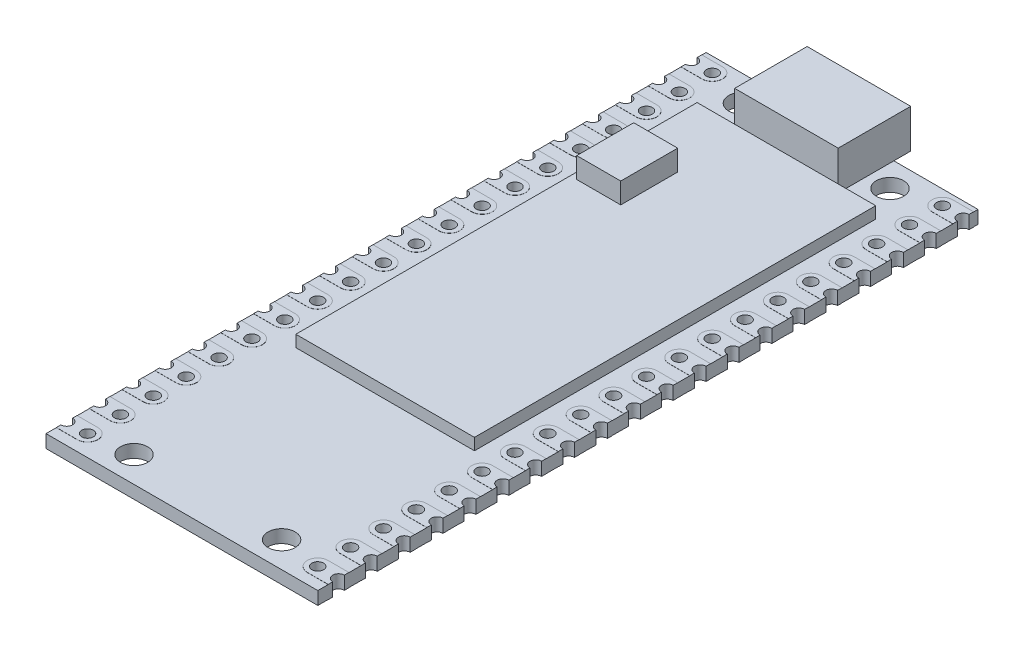
from build123d import *

# Parameters (mm, degrees)
SKETCH1_R                = 1.05
SKETCH1_R_2              = 0.45
BOSS_EXTRUDE1_DEPTH      = 1
SKETCH2_W                = 8
SKETCH2_H                = 5.6
BOSS_EXTRUDE2_DEPTH      = 3
SKETCH3_R                = 0.45
BOSS_EXTRUDE3_DEPTH      = 0.01
BOSS_EXTRUDE3_DEPTH_BACK = 1.01
SKETCH4_W                = 13.8
SKETCH4_H                = 31
BOSS_EXTRUDE4_DEPTH      = 0.9
SKETCH5_W                = 3.4
SKETCH5_H                = 4.4
BOSS_EXTRUDE5_DEPTH      = 2.5


with BuildPart() as part:
    # Sketch1 → Boss-Extrude1 (new body)
    with BuildSketch(Plane(origin=(0, 0, 0), x_dir=(1, 0, 0), z_dir=(0, 1, 0))):
        with BuildLine():
            Line((-10.5, 0), (10.5, 0))
            Line((10.5, 0), (10.5, -0.69))
            ThreePointArc((10.5, -0.69), (10.05, -1.14), (10.5, -1.59))
            Line((10.5, -1.59), (10.5, -3.23))
            ThreePointArc((10.5, -3.23), (10.05, -3.68), (10.5, -4.13))
            Line((10.5, -4.13), (10.5, -5.77))
            ThreePointArc((10.5, -5.77), (10.05, -6.22), (10.5, -6.67))
            Line((10.5, -6.67), (10.5, -8.31))
            ThreePointArc((10.5, -8.31), (10.05, -8.76), (10.5, -9.21))
            Line((10.5, -9.21), (10.5, -10.85))
            ThreePointArc((10.5, -10.85), (10.05, -11.3), (10.5, -11.75))
            Line((10.5, -11.75), (10.5, -13.39))
            ThreePointArc((10.5, -13.39), (10.05, -13.84), (10.5, -14.29))
            Line((10.5, -14.29), (10.5, -15.93))
            ThreePointArc((10.5, -15.93), (10.05, -16.38), (10.5, -16.83))
            Line((10.5, -16.83), (10.5, -18.47))
            ThreePointArc((10.5, -18.47), (10.05, -18.92), (10.5, -19.37))
            Line((10.5, -19.37), (10.5, -21.01))
            ThreePointArc((10.5, -21.01), (10.05, -21.46), (10.5, -21.91))
            Line((10.5, -21.91), (10.5, -23.55))
            ThreePointArc((10.5, -23.55), (10.05, -24), (10.5, -24.45))
            Line((10.5, -24.45), (10.5, -26.09))
            ThreePointArc((10.5, -26.09), (10.05, -26.54), (10.5, -26.99))
            Line((10.5, -26.99), (10.5, -28.63))
            ThreePointArc((10.5, -28.63), (10.05, -29.08), (10.5, -29.53))
            Line((10.5, -29.53), (10.5, -31.17))
            ThreePointArc((10.5, -31.17), (10.05, -31.62), (10.5, -32.07))
            Line((10.5, -32.07), (10.5, -33.71))
            ThreePointArc((10.5, -33.71), (10.05, -34.16), (10.5, -34.61))
            Line((10.5, -34.61), (10.5, -36.25))
            ThreePointArc((10.5, -36.25), (10.05, -36.7), (10.5, -37.15))
            Line((10.5, -37.15), (10.5, -38.79))
            ThreePointArc((10.5, -38.79), (10.05, -39.24), (10.5, -39.69))
            Line((10.5, -39.69), (10.5, -41.33))
            ThreePointArc((10.5, -41.33), (10.05, -41.78), (10.5, -42.23))
            Line((10.5, -42.23), (10.5, -43.87))
            ThreePointArc((10.5, -43.87), (10.05, -44.32), (10.5, -44.77))
            Line((10.5, -44.77), (10.5, -46.41))
            ThreePointArc((10.5, -46.41), (10.05, -46.86), (10.5, -47.31))
            Line((10.5, -47.31), (10.5, -48.95))
            ThreePointArc((10.5, -48.95), (10.05, -49.4), (10.5, -49.85))
            Line((10.5, -49.85), (10.5, -51))
            Line((10.5, -51), (-10.5, -51))
            Line((-10.5, -51), (-10.5, -49.85))
            ThreePointArc((-10.5, -49.85), (-10.05, -49.4), (-10.5, -48.95))
            Line((-10.5, -48.95), (-10.5, -47.31))
            ThreePointArc((-10.5, -47.31), (-10.05, -46.86), (-10.5, -46.41))
            Line((-10.5, -46.41), (-10.5, -44.77))
            ThreePointArc((-10.5, -44.77), (-10.05, -44.32), (-10.5, -43.87))
            Line((-10.5, -43.87), (-10.5, -42.23))
            ThreePointArc((-10.5, -42.23), (-10.05, -41.78), (-10.5, -41.33))
            Line((-10.5, -41.33), (-10.5, -39.69))
            ThreePointArc((-10.5, -39.69), (-10.05, -39.24), (-10.5, -38.79))
            Line((-10.5, -38.79), (-10.5, -37.15))
            ThreePointArc((-10.5, -37.15), (-10.05, -36.7), (-10.5, -36.25))
            Line((-10.5, -36.25), (-10.5, -34.61))
            ThreePointArc((-10.5, -34.61), (-10.05, -34.16), (-10.5, -33.71))
            Line((-10.5, -33.71), (-10.5, -32.07))
            ThreePointArc((-10.5, -32.07), (-10.05, -31.62), (-10.5, -31.17))
            Line((-10.5, -31.17), (-10.5, -29.53))
            ThreePointArc((-10.5, -29.53), (-10.05, -29.08), (-10.5, -28.63))
            Line((-10.5, -28.63), (-10.5, -26.99))
            ThreePointArc((-10.5, -26.99), (-10.05, -26.54), (-10.5, -26.09))
            Line((-10.5, -26.09), (-10.5, -24.45))
            ThreePointArc((-10.5, -24.45), (-10.05, -24), (-10.5, -23.55))
            Line((-10.5, -23.55), (-10.5, -21.91))
            ThreePointArc((-10.5, -21.91), (-10.05, -21.46), (-10.5, -21.01))
            Line((-10.5, -21.01), (-10.5, -19.37))
            ThreePointArc((-10.5, -19.37), (-10.05, -18.92), (-10.5, -18.47))
            Line((-10.5, -18.47), (-10.5, -16.83))
            ThreePointArc((-10.5, -16.83), (-10.05, -16.38), (-10.5, -15.93))
            Line((-10.5, -15.93), (-10.5, -14.29))
            ThreePointArc((-10.5, -14.29), (-10.05, -13.84), (-10.5, -13.39))
            Line((-10.5, -13.39), (-10.5, -11.75))
            ThreePointArc((-10.5, -11.75), (-10.05, -11.3), (-10.5, -10.85))
            Line((-10.5, -10.85), (-10.5, -9.21))
            ThreePointArc((-10.5, -9.21), (-10.05, -8.76), (-10.5, -8.31))
            Line((-10.5, -8.31), (-10.5, -6.67))
            ThreePointArc((-10.5, -6.67), (-10.05, -6.22), (-10.5, -5.77))
            Line((-10.5, -5.77), (-10.5, -4.13))
            ThreePointArc((-10.5, -4.13), (-10.05, -3.68), (-10.5, -3.23))
            Line((-10.5, -3.23), (-10.5, -1.59))
            ThreePointArc((-10.5, -1.59), (-10.05, -1.14), (-10.5, -0.69))
            Line((-10.5, -0.69), (-10.5, 0))
        make_face()
        with Locations(Location((-5.7, -2, 0), (0, 0, 270))):
            Circle(SKETCH1_R, mode=Mode.SUBTRACT)
        with Locations(Location((5.7, -2, 0), (0, 0, 90))):
            Circle(SKETCH1_R, mode=Mode.SUBTRACT)
        with Locations(Location((-8.89, -49.4, 0), (0, 0, 270))):
            Circle(SKETCH1_R_2, mode=Mode.SUBTRACT)
        with Locations(Location((5.7, -49, 0), (0, 0, 270))):
            Circle(SKETCH1_R, mode=Mode.SUBTRACT)
        with Locations(Location((-5.7, -49, 0), (0, 0, 90))):
            Circle(SKETCH1_R, mode=Mode.SUBTRACT)
        with Locations(Location((8.89, -49.4, 0), (0, 0, 90))):
            Circle(SKETCH1_R_2, mode=Mode.SUBTRACT)
        with Locations(Location((-8.89, -46.86, 0), (0, 0, 270))):
            Circle(SKETCH1_R_2, mode=Mode.SUBTRACT)
        with Locations(Location((8.89, -46.86, 0), (0, 0, 90))):
            Circle(SKETCH1_R_2, mode=Mode.SUBTRACT)
        with Locations(Location((-8.89, -44.32, 0), (0, 0, 270))):
            Circle(SKETCH1_R_2, mode=Mode.SUBTRACT)
        with Locations(Location((8.89, -44.32, 0), (0, 0, 90))):
            Circle(SKETCH1_R_2, mode=Mode.SUBTRACT)
        with Locations(Location((-8.89, -41.78, 0), (0, 0, 270))):
            Circle(SKETCH1_R_2, mode=Mode.SUBTRACT)
        with Locations(Location((8.89, -41.78, 0), (0, 0, 90))):
            Circle(SKETCH1_R_2, mode=Mode.SUBTRACT)
        with Locations(Location((-8.89, -39.24, 0), (0, 0, 270))):
            Circle(SKETCH1_R_2, mode=Mode.SUBTRACT)
        with Locations(Location((8.89, -39.24, 0), (0, 0, 90))):
            Circle(SKETCH1_R_2, mode=Mode.SUBTRACT)
        with Locations(Location((-8.89, -36.7, 0), (0, 0, 270))):
            Circle(SKETCH1_R_2, mode=Mode.SUBTRACT)
        with Locations(Location((8.89, -36.7, 0), (0, 0, 90))):
            Circle(SKETCH1_R_2, mode=Mode.SUBTRACT)
        with Locations(Location((-8.89, -34.16, 0), (0, 0, 270))):
            Circle(SKETCH1_R_2, mode=Mode.SUBTRACT)
        with Locations(Location((8.89, -34.16, 0), (0, 0, 90))):
            Circle(SKETCH1_R_2, mode=Mode.SUBTRACT)
        with Locations(Location((-8.89, -31.62, 0), (0, 0, 270))):
            Circle(SKETCH1_R_2, mode=Mode.SUBTRACT)
        with Locations(Location((8.89, -31.62, 0), (0, 0, 90))):
            Circle(SKETCH1_R_2, mode=Mode.SUBTRACT)
        with Locations(Location((-8.89, -29.08, 0), (0, 0, 270))):
            Circle(SKETCH1_R_2, mode=Mode.SUBTRACT)
        with Locations(Location((8.89, -29.08, 0), (0, 0, 90))):
            Circle(SKETCH1_R_2, mode=Mode.SUBTRACT)
        with Locations(Location((-8.89, -26.54, 0), (0, 0, 270))):
            Circle(SKETCH1_R_2, mode=Mode.SUBTRACT)
        with Locations(Location((8.89, -26.54, 0), (0, 0, 90))):
            Circle(SKETCH1_R_2, mode=Mode.SUBTRACT)
        with Locations(Location((-8.89, -24, 0), (0, 0, 270))):
            Circle(SKETCH1_R_2, mode=Mode.SUBTRACT)
        with Locations(Location((8.89, -24, 0), (0, 0, 90))):
            Circle(SKETCH1_R_2, mode=Mode.SUBTRACT)
        with Locations(Location((-8.89, -21.46, 0), (0, 0, 270))):
            Circle(SKETCH1_R_2, mode=Mode.SUBTRACT)
        with Locations(Location((8.89, -21.46, 0), (0, 0, 90))):
            Circle(SKETCH1_R_2, mode=Mode.SUBTRACT)
        with Locations(Location((-8.89, -18.92, 0), (0, 0, 270))):
            Circle(SKETCH1_R_2, mode=Mode.SUBTRACT)
        with Locations(Location((8.89, -18.92, 0), (0, 0, 90))):
            Circle(SKETCH1_R_2, mode=Mode.SUBTRACT)
        with Locations(Location((-8.89, -16.38, 0), (0, 0, 270))):
            Circle(SKETCH1_R_2, mode=Mode.SUBTRACT)
        with Locations(Location((8.89, -16.38, 0), (0, 0, 90))):
            Circle(SKETCH1_R_2, mode=Mode.SUBTRACT)
        with Locations(Location((-8.89, -13.84, 0), (0, 0, 270))):
            Circle(SKETCH1_R_2, mode=Mode.SUBTRACT)
        with Locations(Location((8.89, -13.84, 0), (0, 0, 90))):
            Circle(SKETCH1_R_2, mode=Mode.SUBTRACT)
        with Locations(Location((-8.89, -11.3, 0), (0, 0, 270))):
            Circle(SKETCH1_R_2, mode=Mode.SUBTRACT)
        with Locations(Location((8.89, -11.3, 0), (0, 0, 90))):
            Circle(SKETCH1_R_2, mode=Mode.SUBTRACT)
        with Locations(Location((-8.89, -8.76, 0), (0, 0, 270))):
            Circle(SKETCH1_R_2, mode=Mode.SUBTRACT)
        with Locations(Location((8.89, -8.76, 0), (0, 0, 90))):
            Circle(SKETCH1_R_2, mode=Mode.SUBTRACT)
        with Locations(Location((-8.89, -6.22, 0), (0, 0, 270))):
            Circle(SKETCH1_R_2, mode=Mode.SUBTRACT)
        with Locations(Location((8.89, -6.22, 0), (0, 0, 90))):
            Circle(SKETCH1_R_2, mode=Mode.SUBTRACT)
        with Locations(Location((-8.89, -3.68, 0), (0, 0, 270))):
            Circle(SKETCH1_R_2, mode=Mode.SUBTRACT)
        with Locations(Location((8.89, -3.68, 0), (0, 0, 90))):
            Circle(SKETCH1_R_2, mode=Mode.SUBTRACT)
        with Locations(Location((-8.89, -1.14, 0), (0, 0, 270))):
            Circle(SKETCH1_R_2, mode=Mode.SUBTRACT)
        with Locations(Location((8.89, -1.14, 0), (0, 0, 90))):
            Circle(SKETCH1_R_2, mode=Mode.SUBTRACT)
    extrude(amount=BOSS_EXTRUDE1_DEPTH)

    # Sketch2 → Boss-Extrude2 (add)
    with BuildSketch(Plane(origin=(0, 1, 0), x_dir=(1, 0, 0), z_dir=(0, 1, 0))):
        with Locations((0, -1.5)):
            Rectangle(SKETCH2_W, SKETCH2_H)
    extrude(amount=BOSS_EXTRUDE2_DEPTH)

    # Sketch3 → Boss-Extrude3 (add, two sides)
    with BuildSketch(Plane(origin=(0, 1, 0), x_dir=(1, 0, 0), z_dir=(0, 1, 0))) as boss_extrude3_sk:
        with BuildLine():
            Line((-8.89, -48.6), (-10.5, -48.6))
            Line((-10.5, -48.6), (-10.5, -48.95))
            ThreePointArc((-10.5, -48.95), (-10.05, -49.4), (-10.5, -49.85))
            Line((-10.5, -49.85), (-10.5, -50.2))
            Line((-10.5, -50.2), (-8.89, -50.2))
            ThreePointArc((-8.89, -50.2), (-8.09, -49.4), (-8.89, -48.6))
        make_face()
        with Locations(Location((-8.89, -49.4, 0), (0, 0, 270))):
            Circle(SKETCH3_R, mode=Mode.SUBTRACT)
        with BuildLine():
            Line((10.5, -50.2), (8.89, -50.2))
            ThreePointArc((8.89, -50.2), (8.09, -49.4), (8.89, -48.6))
            Line((8.89, -48.6), (10.5, -48.6))
            Line((10.5, -48.6), (10.5, -48.95))
            ThreePointArc((10.5, -48.95), (10.05, -49.4), (10.5, -49.85))
            Line((10.5, -49.85), (10.5, -50.2))
        make_face()
        with Locations(Location((8.89, -49.4, 0), (0, 0, 90))):
            Circle(SKETCH3_R, mode=Mode.SUBTRACT)
        with BuildLine():
            Line((-8.89, -46.06), (-10.5, -46.06))
            Line((-10.5, -46.06), (-10.5, -46.41))
            ThreePointArc((-10.5, -46.41), (-10.05, -46.86), (-10.5, -47.31))
            Line((-10.5, -47.31), (-10.5, -47.66))
            Line((-10.5, -47.66), (-8.89, -47.66))
            ThreePointArc((-8.89, -47.66), (-8.09, -46.86), (-8.89, -46.06))
        make_face()
        with Locations(Location((-8.89, -46.86, 0), (0, 0, 270))):
            Circle(SKETCH3_R, mode=Mode.SUBTRACT)
        with BuildLine():
            Line((10.5, -47.66), (8.89, -47.66))
            ThreePointArc((8.89, -47.66), (8.09, -46.86), (8.89, -46.06))
            Line((8.89, -46.06), (10.5, -46.06))
            Line((10.5, -46.06), (10.5, -46.41))
            ThreePointArc((10.5, -46.41), (10.05, -46.86), (10.5, -47.31))
            Line((10.5, -47.31), (10.5, -47.66))
        make_face()
        with Locations(Location((8.89, -46.86, 0), (0, 0, 90))):
            Circle(SKETCH3_R, mode=Mode.SUBTRACT)
        with BuildLine():
            Line((-8.89, -43.52), (-10.5, -43.52))
            Line((-10.5, -43.52), (-10.5, -43.87))
            ThreePointArc((-10.5, -43.87), (-10.05, -44.32), (-10.5, -44.77))
            Line((-10.5, -44.77), (-10.5, -45.12))
            Line((-10.5, -45.12), (-8.89, -45.12))
            ThreePointArc((-8.89, -45.12), (-8.09, -44.32), (-8.89, -43.52))
        make_face()
        with Locations(Location((-8.89, -44.32, 0), (0, 0, 270))):
            Circle(SKETCH3_R, mode=Mode.SUBTRACT)
        with BuildLine():
            Line((10.5, -45.12), (8.89, -45.12))
            ThreePointArc((8.89, -45.12), (8.09, -44.32), (8.89, -43.52))
            Line((8.89, -43.52), (10.5, -43.52))
            Line((10.5, -43.52), (10.5, -43.87))
            ThreePointArc((10.5, -43.87), (10.05, -44.32), (10.5, -44.77))
            Line((10.5, -44.77), (10.5, -45.12))
        make_face()
        with Locations(Location((8.89, -44.32, 0), (0, 0, 90))):
            Circle(SKETCH3_R, mode=Mode.SUBTRACT)
        with BuildLine():
            Line((-8.89, -40.98), (-10.5, -40.98))
            Line((-10.5, -40.98), (-10.5, -41.33))
            ThreePointArc((-10.5, -41.33), (-10.05, -41.78), (-10.5, -42.23))
            Line((-10.5, -42.23), (-10.5, -42.58))
            Line((-10.5, -42.58), (-8.89, -42.58))
            ThreePointArc((-8.89, -42.58), (-8.09, -41.78), (-8.89, -40.98))
        make_face()
        with Locations(Location((-8.89, -41.78, 0), (0, 0, 270))):
            Circle(SKETCH3_R, mode=Mode.SUBTRACT)
        with BuildLine():
            Line((10.5, -42.58), (8.89, -42.58))
            ThreePointArc((8.89, -42.58), (8.09, -41.78), (8.89, -40.98))
            Line((8.89, -40.98), (10.5, -40.98))
            Line((10.5, -40.98), (10.5, -41.33))
            ThreePointArc((10.5, -41.33), (10.05, -41.78), (10.5, -42.23))
            Line((10.5, -42.23), (10.5, -42.58))
        make_face()
        with Locations(Location((8.89, -41.78, 0), (0, 0, 90))):
            Circle(SKETCH3_R, mode=Mode.SUBTRACT)
        with BuildLine():
            Line((-8.89, -38.44), (-10.5, -38.44))
            Line((-10.5, -38.44), (-10.5, -38.79))
            ThreePointArc((-10.5, -38.79), (-10.05, -39.24), (-10.5, -39.69))
            Line((-10.5, -39.69), (-10.5, -40.04))
            Line((-10.5, -40.04), (-8.89, -40.04))
            ThreePointArc((-8.89, -40.04), (-8.09, -39.24), (-8.89, -38.44))
        make_face()
        with Locations(Location((-8.89, -39.24, 0), (0, 0, 270))):
            Circle(SKETCH3_R, mode=Mode.SUBTRACT)
        with BuildLine():
            Line((10.5, -40.04), (8.89, -40.04))
            ThreePointArc((8.89, -40.04), (8.09, -39.24), (8.89, -38.44))
            Line((8.89, -38.44), (10.5, -38.44))
            Line((10.5, -38.44), (10.5, -38.79))
            ThreePointArc((10.5, -38.79), (10.05, -39.24), (10.5, -39.69))
            Line((10.5, -39.69), (10.5, -40.04))
        make_face()
        with Locations(Location((8.89, -39.24, 0), (0, 0, 90))):
            Circle(SKETCH3_R, mode=Mode.SUBTRACT)
        with BuildLine():
            Line((-8.89, -35.9), (-10.5, -35.9))
            Line((-10.5, -35.9), (-10.5, -36.25))
            ThreePointArc((-10.5, -36.25), (-10.05, -36.7), (-10.5, -37.15))
            Line((-10.5, -37.15), (-10.5, -37.5))
            Line((-10.5, -37.5), (-8.89, -37.5))
            ThreePointArc((-8.89, -37.5), (-8.09, -36.7), (-8.89, -35.9))
        make_face()
        with Locations(Location((-8.89, -36.7, 0), (0, 0, 270))):
            Circle(SKETCH3_R, mode=Mode.SUBTRACT)
        with BuildLine():
            Line((10.5, -37.5), (8.89, -37.5))
            ThreePointArc((8.89, -37.5), (8.09, -36.7), (8.89, -35.9))
            Line((8.89, -35.9), (10.5, -35.9))
            Line((10.5, -35.9), (10.5, -36.25))
            ThreePointArc((10.5, -36.25), (10.05, -36.7), (10.5, -37.15))
            Line((10.5, -37.15), (10.5, -37.5))
        make_face()
        with Locations(Location((8.89, -36.7, 0), (0, 0, 90))):
            Circle(SKETCH3_R, mode=Mode.SUBTRACT)
        with BuildLine():
            Line((-8.89, -33.36), (-10.5, -33.36))
            Line((-10.5, -33.36), (-10.5, -33.71))
            ThreePointArc((-10.5, -33.71), (-10.05, -34.16), (-10.5, -34.61))
            Line((-10.5, -34.61), (-10.5, -34.96))
            Line((-10.5, -34.96), (-8.89, -34.96))
            ThreePointArc((-8.89, -34.96), (-8.09, -34.16), (-8.89, -33.36))
        make_face()
        with Locations(Location((-8.89, -34.16, 0), (0, 0, 270))):
            Circle(SKETCH3_R, mode=Mode.SUBTRACT)
        with BuildLine():
            Line((10.5, -34.96), (8.89, -34.96))
            ThreePointArc((8.89, -34.96), (8.09, -34.16), (8.89, -33.36))
            Line((8.89, -33.36), (10.5, -33.36))
            Line((10.5, -33.36), (10.5, -33.71))
            ThreePointArc((10.5, -33.71), (10.05, -34.16), (10.5, -34.61))
            Line((10.5, -34.61), (10.5, -34.96))
        make_face()
        with Locations(Location((8.89, -34.16, 0), (0, 0, 90))):
            Circle(SKETCH3_R, mode=Mode.SUBTRACT)
        with BuildLine():
            Line((-8.89, -30.82), (-10.5, -30.82))
            Line((-10.5, -30.82), (-10.5, -31.17))
            ThreePointArc((-10.5, -31.17), (-10.05, -31.62), (-10.5, -32.07))
            Line((-10.5, -32.07), (-10.5, -32.42))
            Line((-10.5, -32.42), (-8.89, -32.42))
            ThreePointArc((-8.89, -32.42), (-8.09, -31.62), (-8.89, -30.82))
        make_face()
        with Locations(Location((-8.89, -31.62, 0), (0, 0, 270))):
            Circle(SKETCH3_R, mode=Mode.SUBTRACT)
        with BuildLine():
            Line((10.5, -32.42), (8.89, -32.42))
            ThreePointArc((8.89, -32.42), (8.09, -31.62), (8.89, -30.82))
            Line((8.89, -30.82), (10.5, -30.82))
            Line((10.5, -30.82), (10.5, -31.17))
            ThreePointArc((10.5, -31.17), (10.05, -31.62), (10.5, -32.07))
            Line((10.5, -32.07), (10.5, -32.42))
        make_face()
        with Locations(Location((8.89, -31.62, 0), (0, 0, 90))):
            Circle(SKETCH3_R, mode=Mode.SUBTRACT)
        with BuildLine():
            Line((-8.89, -28.28), (-10.5, -28.28))
            Line((-10.5, -28.28), (-10.5, -28.63))
            ThreePointArc((-10.5, -28.63), (-10.05, -29.08), (-10.5, -29.53))
            Line((-10.5, -29.53), (-10.5, -29.88))
            Line((-10.5, -29.88), (-8.89, -29.88))
            ThreePointArc((-8.89, -29.88), (-8.09, -29.08), (-8.89, -28.28))
        make_face()
        with Locations(Location((-8.89, -29.08, 0), (0, 0, 270))):
            Circle(SKETCH3_R, mode=Mode.SUBTRACT)
        with BuildLine():
            Line((10.5, -29.88), (8.89, -29.88))
            ThreePointArc((8.89, -29.88), (8.09, -29.08), (8.89, -28.28))
            Line((8.89, -28.28), (10.5, -28.28))
            Line((10.5, -28.28), (10.5, -28.63))
            ThreePointArc((10.5, -28.63), (10.05, -29.08), (10.5, -29.53))
            Line((10.5, -29.53), (10.5, -29.88))
        make_face()
        with Locations(Location((8.89, -29.08, 0), (0, 0, 90))):
            Circle(SKETCH3_R, mode=Mode.SUBTRACT)
        with BuildLine():
            Line((-8.89, -25.74), (-10.5, -25.74))
            Line((-10.5, -25.74), (-10.5, -26.09))
            ThreePointArc((-10.5, -26.09), (-10.05, -26.54), (-10.5, -26.99))
            Line((-10.5, -26.99), (-10.5, -27.34))
            Line((-10.5, -27.34), (-8.89, -27.34))
            ThreePointArc((-8.89, -27.34), (-8.09, -26.54), (-8.89, -25.74))
        make_face()
        with Locations(Location((-8.89, -26.54, 0), (0, 0, 270))):
            Circle(SKETCH3_R, mode=Mode.SUBTRACT)
        with BuildLine():
            Line((10.5, -27.34), (8.89, -27.34))
            ThreePointArc((8.89, -27.34), (8.09, -26.54), (8.89, -25.74))
            Line((8.89, -25.74), (10.5, -25.74))
            Line((10.5, -25.74), (10.5, -26.09))
            ThreePointArc((10.5, -26.09), (10.05, -26.54), (10.5, -26.99))
            Line((10.5, -26.99), (10.5, -27.34))
        make_face()
        with Locations(Location((8.89, -26.54, 0), (0, 0, 90))):
            Circle(SKETCH3_R, mode=Mode.SUBTRACT)
        with BuildLine():
            Line((-8.89, -23.2), (-10.5, -23.2))
            Line((-10.5, -23.2), (-10.5, -23.55))
            ThreePointArc((-10.5, -23.55), (-10.05, -24), (-10.5, -24.45))
            Line((-10.5, -24.45), (-10.5, -24.8))
            Line((-10.5, -24.8), (-8.89, -24.8))
            ThreePointArc((-8.89, -24.8), (-8.09, -24), (-8.89, -23.2))
        make_face()
        with Locations(Location((-8.89, -24, 0), (0, 0, 270))):
            Circle(SKETCH3_R, mode=Mode.SUBTRACT)
        with BuildLine():
            Line((10.5, -24.8), (8.89, -24.8))
            ThreePointArc((8.89, -24.8), (8.09, -24), (8.89, -23.2))
            Line((8.89, -23.2), (10.5, -23.2))
            Line((10.5, -23.2), (10.5, -23.55))
            ThreePointArc((10.5, -23.55), (10.05, -24), (10.5, -24.45))
            Line((10.5, -24.45), (10.5, -24.8))
        make_face()
        with Locations(Location((8.89, -24, 0), (0, 0, 90))):
            Circle(SKETCH3_R, mode=Mode.SUBTRACT)
        with BuildLine():
            Line((-8.89, -20.66), (-10.5, -20.66))
            Line((-10.5, -20.66), (-10.5, -21.01))
            ThreePointArc((-10.5, -21.01), (-10.05, -21.46), (-10.5, -21.91))
            Line((-10.5, -21.91), (-10.5, -22.26))
            Line((-10.5, -22.26), (-8.89, -22.26))
            ThreePointArc((-8.89, -22.26), (-8.09, -21.46), (-8.89, -20.66))
        make_face()
        with Locations(Location((-8.89, -21.46, 0), (0, 0, 270))):
            Circle(SKETCH3_R, mode=Mode.SUBTRACT)
        with BuildLine():
            Line((10.5, -22.26), (8.89, -22.26))
            ThreePointArc((8.89, -22.26), (8.09, -21.46), (8.89, -20.66))
            Line((8.89, -20.66), (10.5, -20.66))
            Line((10.5, -20.66), (10.5, -21.01))
            ThreePointArc((10.5, -21.01), (10.05, -21.46), (10.5, -21.91))
            Line((10.5, -21.91), (10.5, -22.26))
        make_face()
        with Locations(Location((8.89, -21.46, 0), (0, 0, 90))):
            Circle(SKETCH3_R, mode=Mode.SUBTRACT)
        with BuildLine():
            Line((-8.89, -18.12), (-10.5, -18.12))
            Line((-10.5, -18.12), (-10.5, -18.47))
            ThreePointArc((-10.5, -18.47), (-10.05, -18.92), (-10.5, -19.37))
            Line((-10.5, -19.37), (-10.5, -19.72))
            Line((-10.5, -19.72), (-8.89, -19.72))
            ThreePointArc((-8.89, -19.72), (-8.09, -18.92), (-8.89, -18.12))
        make_face()
        with Locations(Location((-8.89, -18.92, 0), (0, 0, 270))):
            Circle(SKETCH3_R, mode=Mode.SUBTRACT)
        with BuildLine():
            Line((10.5, -19.72), (8.89, -19.72))
            ThreePointArc((8.89, -19.72), (8.09, -18.92), (8.89, -18.12))
            Line((8.89, -18.12), (10.5, -18.12))
            Line((10.5, -18.12), (10.5, -18.47))
            ThreePointArc((10.5, -18.47), (10.05, -18.92), (10.5, -19.37))
            Line((10.5, -19.37), (10.5, -19.72))
        make_face()
        with Locations(Location((8.89, -18.92, 0), (0, 0, 90))):
            Circle(SKETCH3_R, mode=Mode.SUBTRACT)
        with BuildLine():
            Line((-8.89, -15.58), (-10.5, -15.58))
            Line((-10.5, -15.58), (-10.5, -15.93))
            ThreePointArc((-10.5, -15.93), (-10.05, -16.38), (-10.5, -16.83))
            Line((-10.5, -16.83), (-10.5, -17.18))
            Line((-10.5, -17.18), (-8.89, -17.18))
            ThreePointArc((-8.89, -17.18), (-8.09, -16.38), (-8.89, -15.58))
        make_face()
        with Locations(Location((-8.89, -16.38, 0), (0, 0, 270))):
            Circle(SKETCH3_R, mode=Mode.SUBTRACT)
        with BuildLine():
            Line((10.5, -17.18), (8.89, -17.18))
            ThreePointArc((8.89, -17.18), (8.09, -16.38), (8.89, -15.58))
            Line((8.89, -15.58), (10.5, -15.58))
            Line((10.5, -15.58), (10.5, -15.93))
            ThreePointArc((10.5, -15.93), (10.05, -16.38), (10.5, -16.83))
            Line((10.5, -16.83), (10.5, -17.18))
        make_face()
        with Locations(Location((8.89, -16.38, 0), (0, 0, 90))):
            Circle(SKETCH3_R, mode=Mode.SUBTRACT)
        with BuildLine():
            Line((-8.89, -13.04), (-10.5, -13.04))
            Line((-10.5, -13.04), (-10.5, -13.39))
            ThreePointArc((-10.5, -13.39), (-10.05, -13.84), (-10.5, -14.29))
            Line((-10.5, -14.29), (-10.5, -14.64))
            Line((-10.5, -14.64), (-8.89, -14.64))
            ThreePointArc((-8.89, -14.64), (-8.09, -13.84), (-8.89, -13.04))
        make_face()
        with Locations(Location((-8.89, -13.84, 0), (0, 0, 270))):
            Circle(SKETCH3_R, mode=Mode.SUBTRACT)
        with BuildLine():
            Line((10.5, -14.64), (8.89, -14.64))
            ThreePointArc((8.89, -14.64), (8.09, -13.84), (8.89, -13.04))
            Line((8.89, -13.04), (10.5, -13.04))
            Line((10.5, -13.04), (10.5, -13.39))
            ThreePointArc((10.5, -13.39), (10.05, -13.84), (10.5, -14.29))
            Line((10.5, -14.29), (10.5, -14.64))
        make_face()
        with Locations(Location((8.89, -13.84, 0), (0, 0, 90))):
            Circle(SKETCH3_R, mode=Mode.SUBTRACT)
        with BuildLine():
            Line((-8.89, -10.5), (-10.5, -10.5))
            Line((-10.5, -10.5), (-10.5, -10.85))
            ThreePointArc((-10.5, -10.85), (-10.05, -11.3), (-10.5, -11.75))
            Line((-10.5, -11.75), (-10.5, -12.1))
            Line((-10.5, -12.1), (-8.89, -12.1))
            ThreePointArc((-8.89, -12.1), (-8.09, -11.3), (-8.89, -10.5))
        make_face()
        with Locations(Location((-8.89, -11.3, 0), (0, 0, 270))):
            Circle(SKETCH3_R, mode=Mode.SUBTRACT)
        with BuildLine():
            Line((10.5, -12.1), (8.89, -12.1))
            ThreePointArc((8.89, -12.1), (8.09, -11.3), (8.89, -10.5))
            Line((8.89, -10.5), (10.5, -10.5))
            Line((10.5, -10.5), (10.5, -10.85))
            ThreePointArc((10.5, -10.85), (10.05, -11.3), (10.5, -11.75))
            Line((10.5, -11.75), (10.5, -12.1))
        make_face()
        with Locations(Location((8.89, -11.3, 0), (0, 0, 90))):
            Circle(SKETCH3_R, mode=Mode.SUBTRACT)
        with BuildLine():
            Line((-8.89, -7.96), (-10.5, -7.96))
            Line((-10.5, -7.96), (-10.5, -8.31))
            ThreePointArc((-10.5, -8.31), (-10.05, -8.76), (-10.5, -9.21))
            Line((-10.5, -9.21), (-10.5, -9.56))
            Line((-10.5, -9.56), (-8.89, -9.56))
            ThreePointArc((-8.89, -9.56), (-8.09, -8.76), (-8.89, -7.96))
        make_face()
        with Locations(Location((-8.89, -8.76, 0), (0, 0, 270))):
            Circle(SKETCH3_R, mode=Mode.SUBTRACT)
        with BuildLine():
            Line((10.5, -9.56), (8.89, -9.56))
            ThreePointArc((8.89, -9.56), (8.09, -8.76), (8.89, -7.96))
            Line((8.89, -7.96), (10.5, -7.96))
            Line((10.5, -7.96), (10.5, -8.31))
            ThreePointArc((10.5, -8.31), (10.05, -8.76), (10.5, -9.21))
            Line((10.5, -9.21), (10.5, -9.56))
        make_face()
        with Locations(Location((8.89, -8.76, 0), (0, 0, 90))):
            Circle(SKETCH3_R, mode=Mode.SUBTRACT)
        with BuildLine():
            Line((-8.89, -5.42), (-10.5, -5.42))
            Line((-10.5, -5.42), (-10.5, -5.77))
            ThreePointArc((-10.5, -5.77), (-10.05, -6.22), (-10.5, -6.67))
            Line((-10.5, -6.67), (-10.5, -7.02))
            Line((-10.5, -7.02), (-8.89, -7.02))
            ThreePointArc((-8.89, -7.02), (-8.09, -6.22), (-8.89, -5.42))
        make_face()
        with Locations(Location((-8.89, -6.22, 0), (0, 0, 270))):
            Circle(SKETCH3_R, mode=Mode.SUBTRACT)
        with BuildLine():
            Line((10.5, -7.02), (8.89, -7.02))
            ThreePointArc((8.89, -7.02), (8.09, -6.22), (8.89, -5.42))
            Line((8.89, -5.42), (10.5, -5.42))
            Line((10.5, -5.42), (10.5, -5.77))
            ThreePointArc((10.5, -5.77), (10.05, -6.22), (10.5, -6.67))
            Line((10.5, -6.67), (10.5, -7.02))
        make_face()
        with Locations(Location((8.89, -6.22, 0), (0, 0, 90))):
            Circle(SKETCH3_R, mode=Mode.SUBTRACT)
        with BuildLine():
            Line((-8.89, -2.88), (-10.5, -2.88))
            Line((-10.5, -2.88), (-10.5, -3.23))
            ThreePointArc((-10.5, -3.23), (-10.05, -3.68), (-10.5, -4.13))
            Line((-10.5, -4.13), (-10.5, -4.48))
            Line((-10.5, -4.48), (-8.89, -4.48))
            ThreePointArc((-8.89, -4.48), (-8.09, -3.68), (-8.89, -2.88))
        make_face()
        with Locations(Location((-8.89, -3.68, 0), (0, 0, 270))):
            Circle(SKETCH3_R, mode=Mode.SUBTRACT)
        with BuildLine():
            Line((10.5, -4.48), (8.89, -4.48))
            ThreePointArc((8.89, -4.48), (8.09, -3.68), (8.89, -2.88))
            Line((8.89, -2.88), (10.5, -2.88))
            Line((10.5, -2.88), (10.5, -3.23))
            ThreePointArc((10.5, -3.23), (10.05, -3.68), (10.5, -4.13))
            Line((10.5, -4.13), (10.5, -4.48))
        make_face()
        with Locations(Location((8.89, -3.68, 0), (0, 0, 90))):
            Circle(SKETCH3_R, mode=Mode.SUBTRACT)
        with BuildLine():
            Line((-8.89, -0.34), (-10.5, -0.34))
            Line((-10.5, -0.34), (-10.5, -0.69))
            ThreePointArc((-10.5, -0.69), (-10.05, -1.14), (-10.5, -1.59))
            Line((-10.5, -1.59), (-10.5, -1.94))
            Line((-10.5, -1.94), (-8.89, -1.94))
            ThreePointArc((-8.89, -1.94), (-8.09, -1.14), (-8.89, -0.34))
        make_face()
        with Locations(Location((-8.89, -1.14, 0), (0, 0, 270))):
            Circle(SKETCH3_R, mode=Mode.SUBTRACT)
        with BuildLine():
            Line((10.5, -1.94), (8.89, -1.94))
            ThreePointArc((8.89, -1.94), (8.09, -1.14), (8.89, -0.34))
            Line((8.89, -0.34), (10.5, -0.34))
            Line((10.5, -0.34), (10.5, -0.69))
            ThreePointArc((10.5, -0.69), (10.05, -1.14), (10.5, -1.59))
            Line((10.5, -1.59), (10.5, -1.94))
        make_face()
        with Locations(Location((8.89, -1.14, 0), (0, 0, 90))):
            Circle(SKETCH3_R, mode=Mode.SUBTRACT)
    extrude(amount=BOSS_EXTRUDE3_DEPTH)
    extrude(boss_extrude3_sk.sketch, amount=-BOSS_EXTRUDE3_DEPTH_BACK)

    # Sketch4 → Boss-Extrude4 (add)
    with BuildSketch(Plane(origin=(0, 1, 0), x_dir=(1, 0, 0), z_dir=(0, 1, 0))):
        with Locations((0.3, -20.1)):
            Rectangle(SKETCH4_W, SKETCH4_H)
    extrude(amount=BOSS_EXTRUDE4_DEPTH)

    # Sketch5 → Boss-Extrude5 (add)
    with BuildSketch(Plane(origin=(0, 1, 0), x_dir=(1, 0, 0), z_dir=(0, 1, 0))):
        with Locations((-4.4, -12.2)):
            Rectangle(SKETCH5_W, SKETCH5_H)
    extrude(amount=BOSS_EXTRUDE5_DEPTH)


solid = part.part
